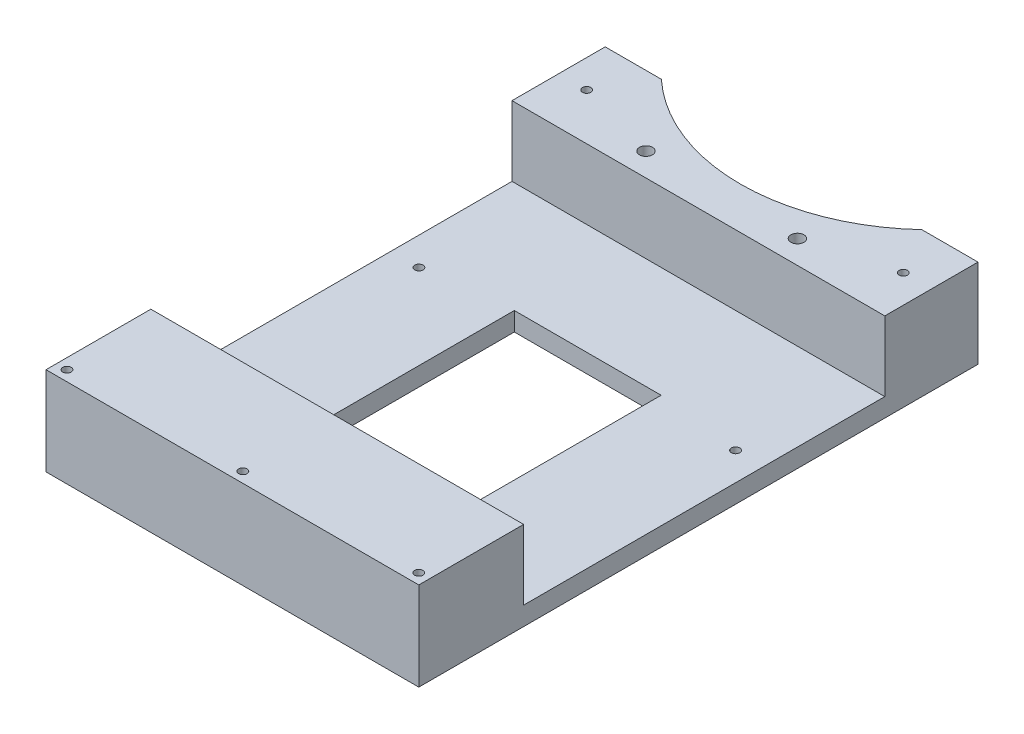
from build123d import *

# Parameters (mm, degrees)
SKETCH_1_R          = 0.9
SKETCH_1_W          = 31.5
SKETCH_1_H          = 49.5
EXTRUDE_1_DEPTH     = 4
SKETCH_2_W          = 80
SKETCH_2_H          = 22.5
EXTRUDE_2_DEPTH     = 15
SKETCH_3_R          = 0.9
CUT_EXTRUDE_1_DEPTH = 20
SKETCH_4_R          = 0.9
CUT_EXTRUDE_2_DEPTH = 20
SKETCH_6_W          = 72
SKETCH_6_H          = 11
CUT_EXTRUDE_3_DEPTH = 18.5
SKETCH_7_R          = 1.4
CUT_EXTRUDE_5_DEPTH = 8


with BuildPart() as part:
    # 스케치1 → 보스-돌출1 (new body)
    with BuildSketch(Plane.XZ):
        with BuildLine():
            Line((45, -52.5), (45, 67.5))
            Line((45, 67.5), (-35, 67.5))
            Line((-35, 67.5), (-35, -52.5))
            Line((-35, -52.5), (-22.946377225, -52.5))
            ThreePointArc((-22.946377225, -52.5), (5, -41.5), (32.946377225, -52.5))
            Line((32.946377225, -52.5), (45, -52.5))
        make_face()
        with Locations((-28.975, -41.744959148)):
            Circle(SKETCH_1_R, mode=Mode.SUBTRACT)
        with Locations((-28.975, -6.5)):
            Circle(SKETCH_1_R, mode=Mode.SUBTRACT)
        with Locations((-32.75, 65.25)):
            Circle(SKETCH_1_R, mode=Mode.SUBTRACT)
        with Locations((5, 65.25)):
            Circle(SKETCH_1_R, mode=Mode.SUBTRACT)
        with Locations((42.75, 65.25)):
            Circle(SKETCH_1_R, mode=Mode.SUBTRACT)
        with Locations((38.975, -6.5)):
            Circle(SKETCH_1_R, mode=Mode.SUBTRACT)
        with Locations((38.975, -41.744959148)):
            Circle(SKETCH_1_R, mode=Mode.SUBTRACT)
        with Locations((5, 16)):
            Rectangle(SKETCH_1_W, SKETCH_1_H, mode=Mode.SUBTRACT)
    extrude(amount=-EXTRUDE_1_DEPTH)

    # 스케치2 → 보스-돌출2 (add)
    with BuildSketch(Plane(origin=(0, 4, 0), x_dir=(1, 0, 0), z_dir=(0, 1, 0))):
        with Locations((5, -56.25)):
            Rectangle(SKETCH_2_W, SKETCH_2_H)
        with BuildLine():
            Line((45, 32.5), (-35, 32.5))
            Line((-35, 32.5), (-35, 52.5))
            Line((-35, 52.5), (-22.946377225, 52.5))
            ThreePointArc((-22.946377225, 52.5), (5, 41.5), (32.946377225, 52.5))
            Line((32.946377225, 52.5), (45, 52.5))
            Line((45, 52.5), (45, 32.5))
        make_face()
    extrude(amount=EXTRUDE_2_DEPTH)

    # 스케치3 → 컷-돌출1 (cut, through all)
    with BuildSketch(Plane(origin=(0, 19, 0), x_dir=(1, 0, 0), z_dir=(0, 1, 0))):
        with Locations((38.975, 42.5)):
            Circle(SKETCH_3_R)
        with Locations((-28.975, 42.5)):
            Circle(SKETCH_3_R)
    extrude(amount=-CUT_EXTRUDE_1_DEPTH, mode=Mode.SUBTRACT)

    # 스케치4 → 컷-돌출2 (cut, through all)
    with BuildSketch(Plane.XZ):
        with Locations((42.75, 65.25)):
            Circle(SKETCH_4_R)
        with Locations((5, 65.25)):
            Circle(SKETCH_4_R)
        with Locations((-32.75, 65.25)):
            Circle(SKETCH_4_R)
    extrude(amount=-CUT_EXTRUDE_2_DEPTH, mode=Mode.SUBTRACT)

    # 스케치6 → 컷-돌출3 (cut)
    with BuildSketch(Plane(origin=(0, 0, 45), x_dir=(-1, 0, 0), z_dir=(0, 0, -1))):
        with Locations((-5, 9.5)):
            Rectangle(SKETCH_6_W, SKETCH_6_H)
    extrude(amount=-CUT_EXTRUDE_3_DEPTH, mode=Mode.SUBTRACT)

    # 스케치7 → 컷-돌출5 (cut)
    with BuildSketch(Plane(origin=(0, 19, 0), x_dir=(1, 0, 0), z_dir=(0, 1, 0))):
        with Locations((21.25, 37.5)):
            Circle(SKETCH_7_R)
        with Locations((-11.25, 37.5)):
            Circle(SKETCH_7_R)
    extrude(amount=-CUT_EXTRUDE_5_DEPTH, mode=Mode.SUBTRACT)


solid = part.part
